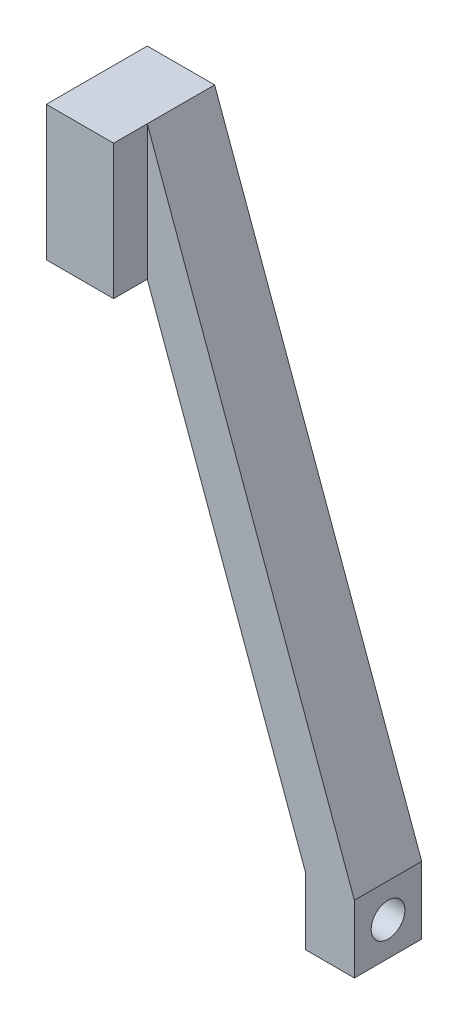
from build123d import *

# Parameters (mm, degrees)
BOSS_EXTRUDE1_DEPTH = 12.7
SKETCH2_R           = 3.175
CUT_EXTRUDE1_DEPTH  = 10.24484395
SKETCH5_W           = 12.7
SKETCH5_H           = 25.4
BOSS_EXTRUDE2_DEPTH = 6.35
SKETCH4_R           = 3.175
CUT_EXTRUDE2_DEPTH  = 19.05
CUT_EXTRUDE3_DEPTH  = 20.05


with BuildPart() as part:
    # Sketch1 → Boss-Extrude1 (new body)
    with BuildSketch(Plane.XY):
        Polygon((0, 0), (0, 25.4), (12.7, 25.4), (51.754006137, -81.9), (51.754006137, -94.6), (42.509162186, -94.6), (42.509162186, -81.9), (12.7, 0), align=None)
    boss_extrude1 = extrude(amount=-BOSS_EXTRUDE1_DEPTH)

    # Sketch2 → Cut-Extrude1 (cut, through all)
    with BuildSketch(Plane.ZY.offset(-42.509162186)):
        with Locations((-6.35, -88.25)):
            Circle(SKETCH2_R)
    cut_extrude1 = extrude(amount=-CUT_EXTRUDE1_DEPTH, mode=Mode.SUBTRACT)

    # Sketch5 → Boss-Extrude2 (add)
    with BuildSketch(Plane.XY.offset(-12.7)):
        with Locations((6.35, 12.7)):
            Rectangle(SKETCH5_W, SKETCH5_H)
    boss_extrude2 = extrude(amount=-BOSS_EXTRUDE2_DEPTH)

    # Sketch4 → Cut-Extrude2 (cut)
    with BuildSketch(Plane.XZ):
        with Locations((6.35, -12.7)):
            Circle(SKETCH4_R)
    cut_extrude2 = extrude(amount=-CUT_EXTRUDE2_DEPTH, mode=Mode.SUBTRACT)

    # Mirror2: Boss-Extrude1, Cut-Extrude1, Boss-Extrude2, Cut-Extrude2 across plane
    add(boss_extrude1.mirror(Plane(origin=(42.509162186, 0, 0), x_dir=(1, 0, 0), z_dir=(0, 0, -1))))
    add(cut_extrude1.mirror(Plane(origin=(42.509162186, 0, 0), x_dir=(1, 0, 0), z_dir=(0, 0, -1))), mode=Mode.SUBTRACT)
    add(boss_extrude2.mirror(Plane(origin=(42.509162186, 0, 0), x_dir=(1, 0, 0), z_dir=(0, 0, -1))))
    add(cut_extrude2.mirror(Plane(origin=(42.509162186, 0, 0), x_dir=(1, 0, 0), z_dir=(0, 0, -1))), mode=Mode.SUBTRACT)

    # Sketch6 → Cut-Extrude3 (cut, through all)
    with BuildSketch(Plane.XY):
        Polygon((12.7, 25.4), (0, 25.4), (0, 0), (12.7, 0), (42.509162186, -81.9), (42.509162186, -94.6), (51.754006137, -94.6), (51.754006137, -81.9), align=None)
    extrude(amount=-CUT_EXTRUDE3_DEPTH, mode=Mode.SUBTRACT)


solid = part.part
